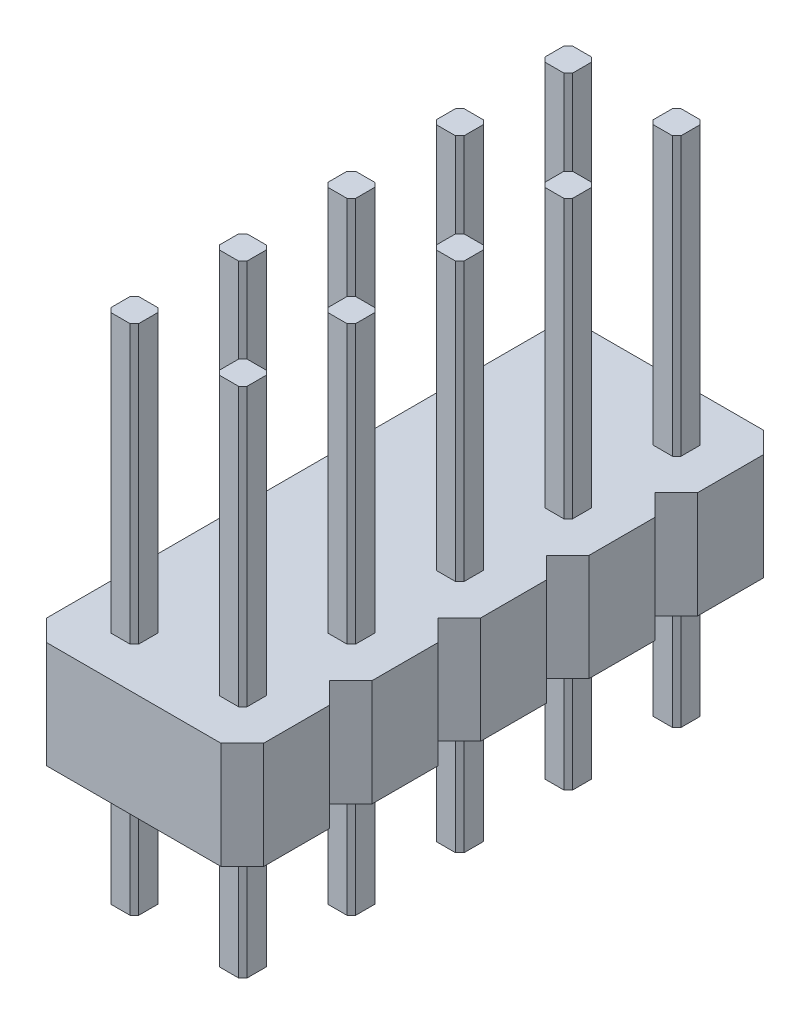
from build123d import *

# Parameters (mm, degrees)
BOSS_EXTRUDE1_DEPTH = 12
LPATTERN1_COUNT     = 2
LPATTERN1_PITCH     = 2.54
BOSS_EXTRUDE2_DEPTH = 2.5
LPATTERN2_COUNT     = 5
LPATTERN2_PITCH     = 2.54


with BuildPart() as part:
    # Sketch1 → Boss-Extrude1 (new body)
    with BuildSketch(Plane(origin=(0, 0, 0), x_dir=(1, 0, 0), z_dir=(0, 1, 0))):
        Polygon((-0.325, 0.225), (-0.225, 0.325), (0.225, 0.325), (0.325, 0.225), (0.325, -0.225), (0.225, -0.325), (-0.225, -0.325), (-0.325, -0.225), align=None)
    extrude(amount=BOSS_EXTRUDE1_DEPTH)


with BuildPart() as lpattern1_1:
    # LPattern1: pattern copy
    add(part.part.moved(Location(Vector(1, 0, 0) * (1 * LPATTERN1_PITCH))))


with BuildPart() as part_1:
    add(part.part)

    add(lpattern1_1.part)  # Boss-Extrude2 merges LPattern1_1
    # Sketch2 → Boss-Extrude2 (add)
    with BuildSketch(Plane(origin=(0, 3, 0), x_dir=(-1, 0, 0), z_dir=(0, -1, 0))):
        Polygon((-3.797398843, -0.77), (-3.297398843, -1.27), (0.782601157, -1.27), (1.282601157, -0.77), (1.282601157, 0.77), (0.782601157, 1.27), (-3.297398843, 1.27), (-3.797398843, 0.77), align=None)
    extrude(amount=-BOSS_EXTRUDE2_DEPTH)


with BuildPart() as lpattern2_1:
    # LPattern2: pattern copy
    add(part_1.part.moved(Location(Vector(0, 0, 1) * (1 * LPATTERN2_PITCH))))


with BuildPart() as lpattern2_2:
    # LPattern2: pattern copy
    add(part_1.part.moved(Location(Vector(0, 0, 1) * (2 * LPATTERN2_PITCH))))


with BuildPart() as lpattern2_3:
    # LPattern2: pattern copy
    add(part_1.part.moved(Location(Vector(0, 0, 1) * (3 * LPATTERN2_PITCH))))


with BuildPart() as lpattern2_4:
    # LPattern2: pattern copy
    add(part_1.part.moved(Location(Vector(0, 0, 1) * (4 * LPATTERN2_PITCH))))


with BuildPart() as part_2:
    add(part_1.part)

    # Combine1: union LPattern2_1, LPattern2_2, LPattern2_3, LPattern2_4
    add(lpattern2_1.part)
    add(lpattern2_2.part)
    add(lpattern2_3.part)
    add(lpattern2_4.part)


solid = part_2.part
